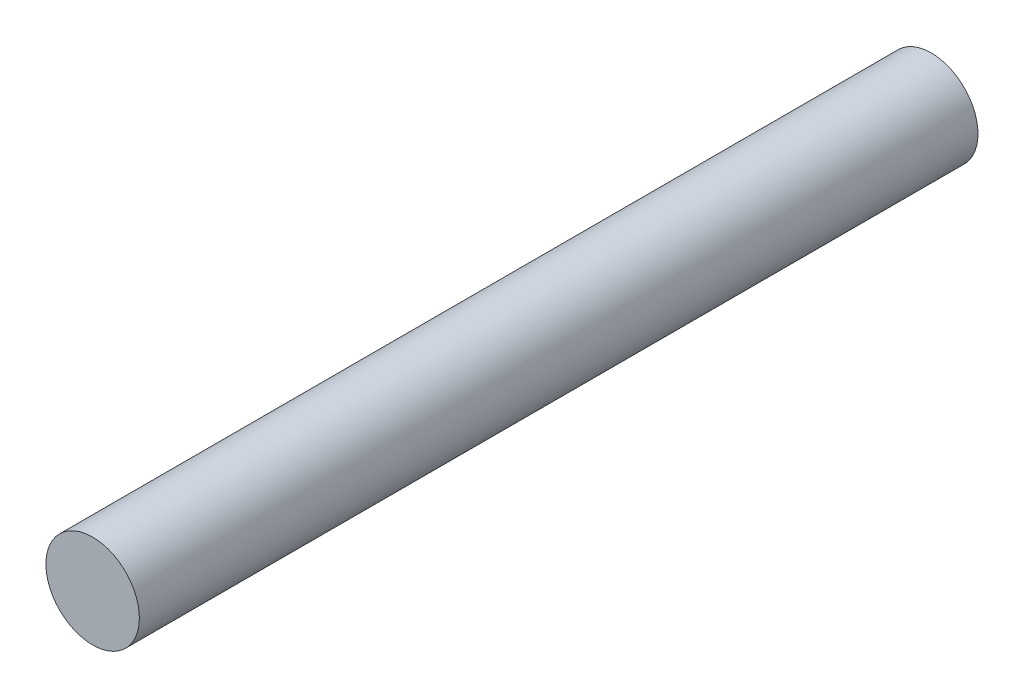
from build123d import *

# Parameters (mm, degrees)
SKETCH_1_R      = 1.95
EXTRUDE_1_DEPTH = 35


with BuildPart() as part:
    # 스케치1 → 보스-돌출1 (new body)
    with BuildSketch(Plane.XY):
        Circle(SKETCH_1_R)
    extrude(amount=EXTRUDE_1_DEPTH)


solid = part.part
